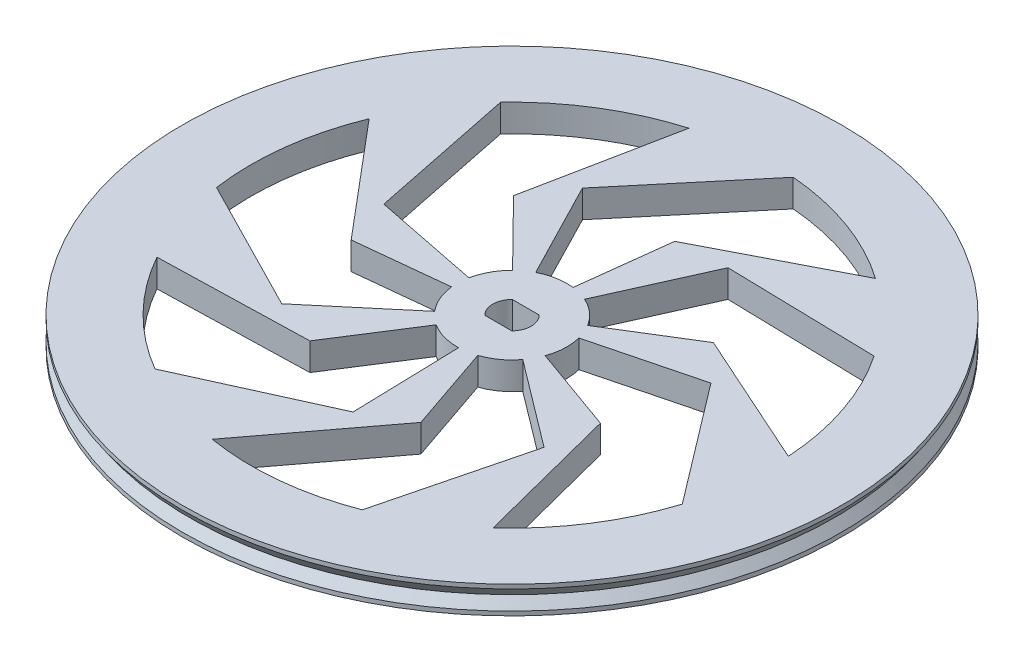
from build123d import *

# Parameters (mm, degrees)
CUT_EXTRUDE1_DEPTH = 7.35


with BuildPart() as part:
    # Sketch1 → Revolve1 (revolve)
    with BuildSketch(Plane(origin=(0, 0, 0), x_dir=(0, 0, -1), z_dir=(1, 0, 0))):
        Polygon((74.67454347, 0), (76.2, 2.210784201), (76.2, 3.175), (0, 3.175), (0, -3.175), (76.2, -3.175), (76.2, -2.210784201), align=None)
    revolve(axis=Axis((0, -3.175, 0), (0, 1, 0)))

    # Sketch2 → Cut-Extrude1 (cut, through all)
    with BuildSketch(Plane(origin=(0, 3.175, 0), x_dir=(1, 0, 0), z_dir=(0, 1, 0))):
        with BuildLine():
            Line((-3.110851973, 3.175), (3.110851973, 3.175))
            ThreePointArc((3.110851973, 3.175), (4.445, 0), (3.110851973, -3.175))
            Line((3.110851973, -3.175), (-3.110851973, -3.175))
            ThreePointArc((-3.110851973, -3.175), (-4.445, 0), (-3.110851973, 3.175))
        make_face()
        with BuildLine():
            Line((-17.302740061, 33.589551898), (4.896011221, 60.125990213))
            ThreePointArc((4.896011221, 60.125990213), (20.500009374, 56.734956073), (34.667618402, 49.368632342))
            Line((34.667618402, 49.368632342), (4.035924256, 33.589551898))
            Line((4.035924256, 33.589551898), (1.51506049, 12.609305759))
            ThreePointArc((1.51506049, 12.609305759), (-2.249253525, 12.49923432), (-5.815791429, 11.290109391))
            Line((-5.815791429, 11.290109391), (-17.302740061, 33.589551898))
        make_face()
        with BuildLine():
            Line((15.473287184, 34.470569971), (50.061005129, 33.660086013))
            ThreePointArc((50.061005129, 33.660086013), (57.138721597, 19.346113801), (60.21285754, 3.676603308))
            Line((60.21285754, 3.676603308), (28.777726771, 17.787330414))
            Line((28.777726771, 17.787330414), (10.802976979, 6.67725156))
            ThreePointArc((10.802976979, 6.67725156), (8.369908264, 9.551682347), (5.200876316, 11.586236902))
            Line((5.200876316, 11.586236902), (15.473287184, 34.470569971))
        make_face()
        with BuildLine():
            Line((36.597613582, 9.394545783), (57.529041117, -18.152549495))
            ThreePointArc((57.529041117, -18.152549495), (50.75081104, -32.610746752), (40.416586831, -44.783983006))
            Line((40.416586831, -44.783983006), (31.849314069, -11.409113668))
            Line((31.849314069, -11.409113668), (11.956031462, -4.282909254))
            ThreePointArc((11.956031462, -4.282909254), (12.686358414, -0.588481252), (12.301178117, 3.15769171))
            Line((12.301178117, 3.15769171), (36.597613582, 9.394545783))
        make_face()
        with BuildLine():
            Line((30.163190498, -22.755762993), (21.676535765, -56.295944989))
            ThreePointArc((21.676535765, -56.295944989), (6.146504642, -60.011049863), (-9.814198109, -59.52131669))
            Line((-9.814198109, -59.52131669), (10.937718265, -32.014262454))
            Line((10.937718265, -32.014262454), (4.105950396, -12.017952045))
            ThreePointArc((4.105950396, -12.017952045), (7.449721924, -10.285506465), (10.138441898, -7.648659745))
            Line((10.138441898, -7.648659745), (30.163190498, -22.755762993))
        make_face()
        with BuildLine():
            Line((1.015269752, -37.770518102), (-30.498843139, -52.047345679))
            ThreePointArc((-30.498843139, -52.047345679), (-43.086245118, -42.221808425), (-52.6546917, -29.437884892))
            Line((-52.6546917, -29.437884892), (-18.210202481, -28.512018641))
            Line((-18.210202481, -28.512018641), (-6.835995065, -10.703231824))
            ThreePointArc((-6.835995065, -10.703231824), (-3.396707121, -12.237335524), (0.341252143, -12.695414407))
            Line((0.341252143, -12.695414407), (1.015269752, -37.770518102))
        make_face()
        with BuildLine():
            Line((-28.897169825, -24.343302703), (-59.707971096, -8.606033499))
            ThreePointArc((-59.707971096, -8.606033499), (-59.874173504, 7.361315925), (-55.845128481, 22.812874653))
            Line((-55.845128481, 22.812874653), (-33.645469338, -3.539643251))
            Line((-33.645469338, -3.539643251), (-12.630296812, -1.328759734))
            ThreePointArc((-12.630296812, -1.328759734), (-11.685346424, -4.974201337), (-9.712907436, -8.182263082))
            Line((-9.712907436, -8.182263082), (-28.897169825, -24.343302703))
        make_face()
        with BuildLine():
            Line((-37.049451129, 7.414916145), (-43.955778997, 41.315797436))
            ThreePointArc((-43.955778997, 41.315797436), (-31.575628032, 51.40121924), (-16.983044483, 57.885074286))
            Line((-16.983044483, 57.885074286), (-23.745011542, 24.098155702))
            Line((-23.745011542, 24.098155702), (-8.913727449, 9.046295538))
            ThreePointArc((-8.913727449, 9.046295538), (-11.174681532, 6.034607912), (-12.453049608, 2.492299232))
            Line((-12.453049608, 2.492299232), (-37.049451129, 7.414916145))
        make_face()
    extrude(amount=-CUT_EXTRUDE1_DEPTH, mode=Mode.SUBTRACT)


solid = part.part
